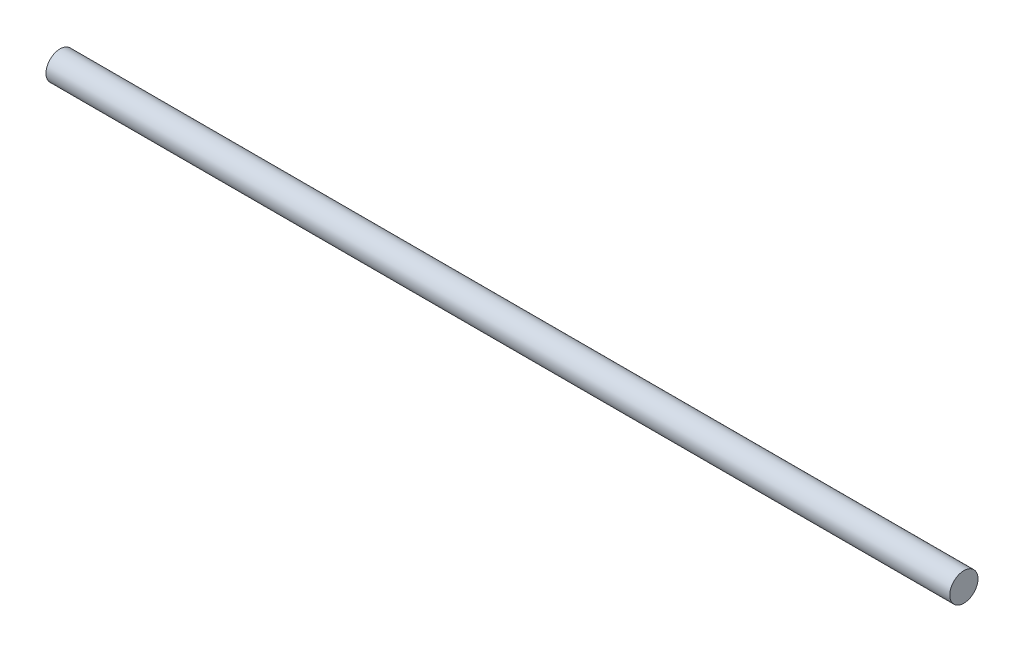
from build123d import *

# Parameters (mm, degrees)
MUSCLEDIAMETER_R   = 12.5
MUSCLELENGTH_DEPTH = 800


with BuildPart() as part:
    # MuscleDiameter → MuscleLength (new body)
    with BuildSketch(Plane(origin=(0, 0, 0), x_dir=(0, 0, -1), z_dir=(1, 0, 0))):
        Circle(MUSCLEDIAMETER_R)
    extrude(amount=MUSCLELENGTH_DEPTH)


solid = part.part
